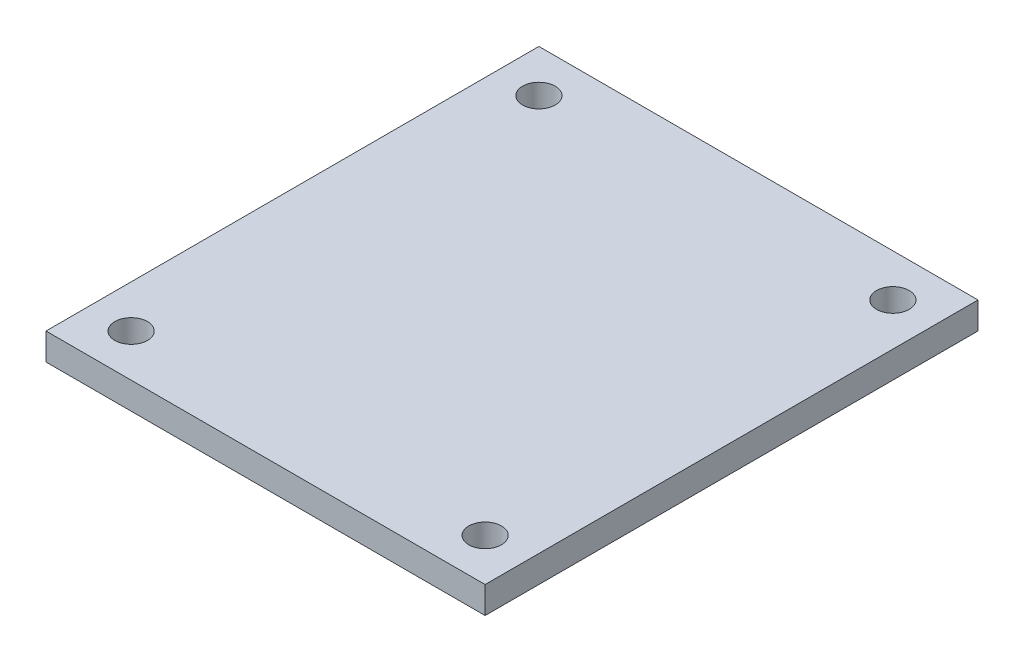
from build123d import *

# Parameters (mm, degrees)
ESQUISSE1_W             = 98
ESQUISSE1_H             = 110
BOSS_EXTRU_1_DEPTH      = 6
ESQUISSE2_R             = 3.65
ENL_V_MAT_EXTRU_1_DEPTH = 7


with BuildPart() as part:
    # Esquisse1 → Boss.-Extru.1 (new body)
    with BuildSketch(Plane(origin=(0, 0, 0), x_dir=(1, 0, 0), z_dir=(0, 1, 0))):
        with Locations((49, 55)):
            Rectangle(ESQUISSE1_W, ESQUISSE1_H)
    extrude(amount=BOSS_EXTRU_1_DEPTH)

    # Esquisse2 → Enlèv. mat.-Extru.1 (cut, through all)
    with BuildSketch(Plane(origin=(0, 6, 0), x_dir=(1, 0, 0), z_dir=(0, 1, 0))):
        with Locations((9.5, 100.5)):
            Circle(ESQUISSE2_R)
        with Locations((88.5, 100.5)):
            Circle(ESQUISSE2_R)
        with Locations((88.5, 9.5)):
            Circle(ESQUISSE2_R)
        with Locations((9.5, 9.5)):
            Circle(ESQUISSE2_R)
    extrude(amount=-ENL_V_MAT_EXTRU_1_DEPTH, mode=Mode.SUBTRACT)


solid = part.part
